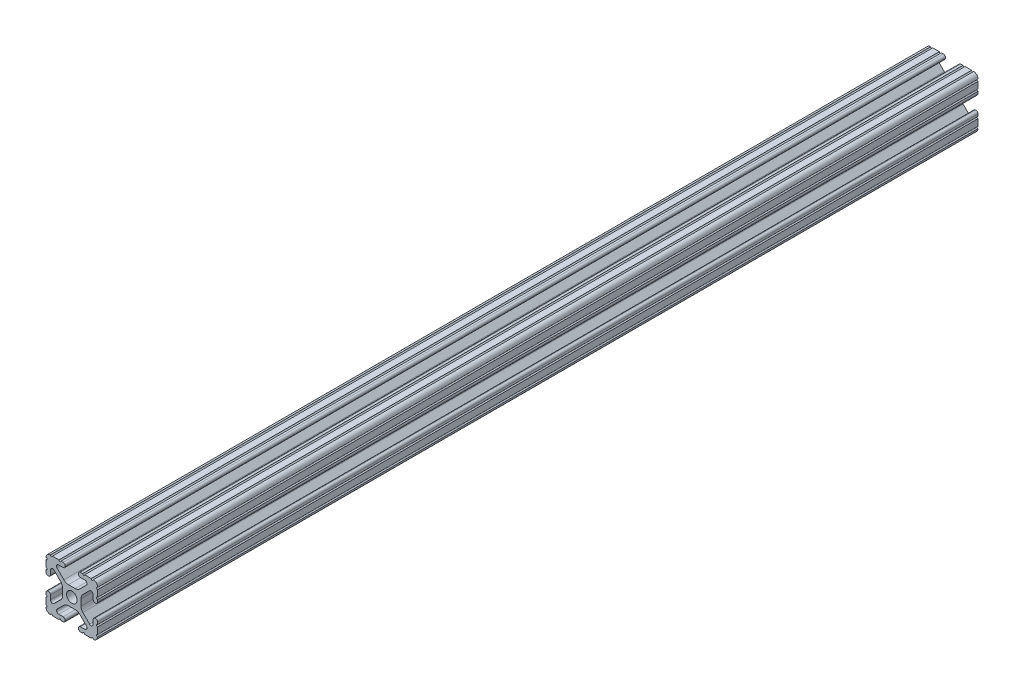
from build123d import *

# Parameters (mm, degrees)
SKETCH1_R           = 2.6035
BOSS_EXTRUDE1_DEPTH = 304.8
SKETCH2_W           = 49.977266258
SKETCH2_H           = 47.000485055
CUT_EXTRUDE1_DEPTH  = 176.53


with BuildPart() as part:
    # Sketch1 → Boss-Extrude1 (new body, symmetric)
    with BuildSketch(Plane.XY):
        with BuildLine():
            Line((-7.179650497, -8.645192506), (-3.952270251, -5.423690499))
            ThreePointArc((-3.952270251, -5.423690499), (-2.922936451, -4.736929036), (-1.709253557, -4.4958))
            Line((-1.709253557, -4.4958), (1.709253557, -4.4958))
            ThreePointArc((1.709253557, -4.4958), (2.922936451, -4.736929036), (3.952270251, -5.423690499))
            Line((3.952270251, -5.423690499), (7.179650497, -8.645192506))
            ThreePointArc((7.179650497, -8.645192506), (7.41473083, -9.822813117), (6.416408329, -10.4902))
            Line((6.416408329, -10.4902), (4.287512407, -10.4902))
            ThreePointArc((4.287512407, -10.4902), (3.54574862, -10.79744862), (3.2385, -11.539212407))
            Line((3.2385, -11.539212407), (3.2385, -11.650987593))
            ThreePointArc((3.2385, -11.650987593), (3.54574862, -12.39275138), (4.287512407, -12.7))
            Line((4.287512407, -12.7), (5.317126718, -12.7))
            ThreePointArc((5.317126718, -12.7), (5.825126718, -12.192), (6.333126718, -12.7))
            Line((6.333126718, -12.7), (9.550443118, -12.7))
            ThreePointArc((9.550443118, -12.7), (10.058366869, -12.192000006), (10.566443095, -12.699847501))
            ThreePointArc((10.566443095, -12.699847501), (12.082537762, -12.08250727), (12.699846982, -10.566399977))
            ThreePointArc((12.699846982, -10.566399977), (12.192000006, -10.058323491), (12.7, -9.5504))
            Line((12.7, -9.5504), (12.7, -6.3330836))
            ThreePointArc((12.7, -6.3330836), (12.192, -5.8250836), (12.7, -5.3170836))
            Line((12.7, -5.3170836), (12.7, -4.287469289))
            ThreePointArc((12.7, -4.287469289), (12.39275138, -3.545705502), (11.650987593, -3.238456882))
            Line((11.650987593, -3.238456882), (11.539212407, -3.238456882))
            ThreePointArc((11.539212407, -3.238456882), (10.79744862, -3.545705502), (10.4902, -4.287469289))
            Line((10.4902, -4.287469289), (10.4902, -6.402089023))
            ThreePointArc((10.4902, -6.402089023), (9.856505071, -7.351067942), (8.737131347, -7.129408934))
            Line((8.737131347, -7.129408934), (5.441005833, -3.840816462))
            ThreePointArc((5.441005833, -3.840816462), (4.750877967, -2.809883091), (4.5085, -1.593185507))
            Line((4.5085, -1.593185507), (4.5085, 1.593185507))
            ThreePointArc((4.5085, 1.593185507), (4.750877967, 2.809883091), (5.441005833, 3.840816462))
            Line((5.441005833, 3.840816462), (8.737131347, 7.129408934))
            ThreePointArc((8.737131347, 7.129408934), (9.856505071, 7.351067942), (10.4902, 6.402089023))
            Line((10.4902, 6.402089023), (10.4902, 4.287469289))
            ThreePointArc((10.4902, 4.287469289), (10.79744862, 3.545705502), (11.539212407, 3.238456882))
            Line((11.539212407, 3.238456882), (11.650987593, 3.238456882))
            ThreePointArc((11.650987593, 3.238456882), (12.39275138, 3.545705502), (12.7, 4.287469289))
            Line((12.7, 4.287469289), (12.7, 5.3170836))
            ThreePointArc((12.7, 5.3170836), (12.192, 5.8250836), (12.7, 6.3330836))
            Line((12.7, 6.3330836), (12.7, 9.5504))
            ThreePointArc((12.7, 9.5504), (12.192000006, 10.058323491), (12.699846982, 10.566399977))
            ThreePointArc((12.699846982, 10.566399977), (12.082537762, 12.08250727), (10.566443095, 12.699847501))
            ThreePointArc((10.566443095, 12.699847501), (10.058366869, 12.192000006), (9.550443118, 12.7))
            Line((9.550443118, 12.7), (6.333126718, 12.7))
            ThreePointArc((6.333126718, 12.7), (5.825126718, 12.192), (5.317126718, 12.7))
            Line((5.317126718, 12.7), (4.287512407, 12.7))
            ThreePointArc((4.287512407, 12.7), (3.54574862, 12.39275138), (3.2385, 11.650987593))
            Line((3.2385, 11.650987593), (3.2385, 11.539212407))
            ThreePointArc((3.2385, 11.539212407), (3.54574862, 10.79744862), (4.287512407, 10.4902))
            Line((4.287512407, 10.4902), (6.476788598, 10.4902))
            ThreePointArc((6.476788598, 10.4902), (7.432222385, 9.85140422), (7.207036008, 8.724370562))
            Line((7.207036008, 8.724370562), (3.898272566, 5.423169045))
            ThreePointArc((3.898272566, 5.423169045), (2.869120213, 4.736787962), (1.655778399, 4.4958))
            Line((1.655778399, 4.4958), (-1.655778399, 4.4958))
            ThreePointArc((-1.655778399, 4.4958), (-2.869120213, 4.736787962), (-3.898272566, 5.423169045))
            Line((-3.898272566, 5.423169045), (-7.207036008, 8.724370562))
            ThreePointArc((-7.207036008, 8.724370562), (-7.432222385, 9.85140422), (-6.476788598, 10.4902))
            Line((-6.476788598, 10.4902), (-4.287512407, 10.4902))
            ThreePointArc((-4.287512407, 10.4902), (-3.54574862, 10.79744862), (-3.2385, 11.539212407))
            Line((-3.2385, 11.539212407), (-3.2385, 11.650987593))
            ThreePointArc((-3.2385, 11.650987593), (-3.54574862, 12.39275138), (-4.287512407, 12.7))
            Line((-4.287512407, 12.7), (-5.317126718, 12.7))
            ThreePointArc((-5.317126718, 12.7), (-5.825126718, 12.192), (-6.333126718, 12.7))
            Line((-6.333126718, 12.7), (-9.550443118, 12.7))
            ThreePointArc((-9.550443118, 12.7), (-10.058366869, 12.192000006), (-10.566443095, 12.699847501))
            ThreePointArc((-10.566443095, 12.699847501), (-12.082537762, 12.08250727), (-12.699846982, 10.566399977))
            ThreePointArc((-12.699846982, 10.566399977), (-12.192000006, 10.058323491), (-12.7, 9.5504))
            Line((-12.7, 9.5504), (-12.7, 6.3330836))
            ThreePointArc((-12.7, 6.3330836), (-12.192, 5.8250836), (-12.7, 5.3170836))
            Line((-12.7, 5.3170836), (-12.7, 4.287469289))
            ThreePointArc((-12.7, 4.287469289), (-12.39275138, 3.545705502), (-11.650987593, 3.238456882))
            Line((-11.650987593, 3.238456882), (-11.539212407, 3.238456882))
            ThreePointArc((-11.539212407, 3.238456882), (-10.79744862, 3.545705502), (-10.4902, 4.287469289))
            Line((-10.4902, 4.287469289), (-10.4902, 6.402089023))
            ThreePointArc((-10.4902, 6.402089023), (-9.856505071, 7.351067942), (-8.737131347, 7.129408934))
            Line((-8.737131347, 7.129408934), (-5.441005833, 3.840816462))
            ThreePointArc((-5.441005833, 3.840816462), (-4.750877967, 2.809883091), (-4.5085, 1.593185507))
            Line((-4.5085, 1.593185507), (-4.5085, -1.593185507))
            ThreePointArc((-4.5085, -1.593185507), (-4.750877967, -2.809883091), (-5.441005833, -3.840816462))
            Line((-5.441005833, -3.840816462), (-8.737131347, -7.129408934))
            ThreePointArc((-8.737131347, -7.129408934), (-9.856505071, -7.351067942), (-10.4902, -6.402089023))
            Line((-10.4902, -6.402089023), (-10.4902, -4.287469289))
            ThreePointArc((-10.4902, -4.287469289), (-10.79744862, -3.545705502), (-11.539212407, -3.238456882))
            Line((-11.539212407, -3.238456882), (-11.650987593, -3.238456882))
            ThreePointArc((-11.650987593, -3.238456882), (-12.39275138, -3.545705502), (-12.7, -4.287469289))
            Line((-12.7, -4.287469289), (-12.7, -5.3170836))
            ThreePointArc((-12.7, -5.3170836), (-12.192, -5.8250836), (-12.7, -6.3330836))
            Line((-12.7, -6.3330836), (-12.7, -9.5504))
            ThreePointArc((-12.7, -9.5504), (-12.192000006, -10.058323491), (-12.699846982, -10.566399977))
            ThreePointArc((-12.699846982, -10.566399977), (-12.082537762, -12.08250727), (-10.566443095, -12.699847501))
            ThreePointArc((-10.566443095, -12.699847501), (-10.058366869, -12.192000006), (-9.550443118, -12.7))
            Line((-9.550443118, -12.7), (-6.333126718, -12.7))
            ThreePointArc((-6.333126718, -12.7), (-5.825126718, -12.192), (-5.317126718, -12.7))
            Line((-5.317126718, -12.7), (-4.287512407, -12.7))
            ThreePointArc((-4.287512407, -12.7), (-3.54574862, -12.39275138), (-3.2385, -11.650987593))
            Line((-3.2385, -11.650987593), (-3.2385, -11.539212407))
            ThreePointArc((-3.2385, -11.539212407), (-3.54574862, -10.79744862), (-4.287512407, -10.4902))
            Line((-4.287512407, -10.4902), (-6.416408329, -10.4902))
            ThreePointArc((-6.416408329, -10.4902), (-7.41473083, -9.822813117), (-7.179650497, -8.645192506))
        make_face()
        Circle(SKETCH1_R, mode=Mode.SUBTRACT)
    extrude(amount=BOSS_EXTRUDE1_DEPTH, both=True)

    # Sketch2 → Cut-Extrude1 (cut)
    with BuildSketch(Plane.XY.offset(304.8)):
        with Locations((1.177518628, -0.126321905)):
            Rectangle(SKETCH2_W, SKETCH2_H)
    extrude(amount=-CUT_EXTRUDE1_DEPTH, mode=Mode.SUBTRACT)


solid = part.part
